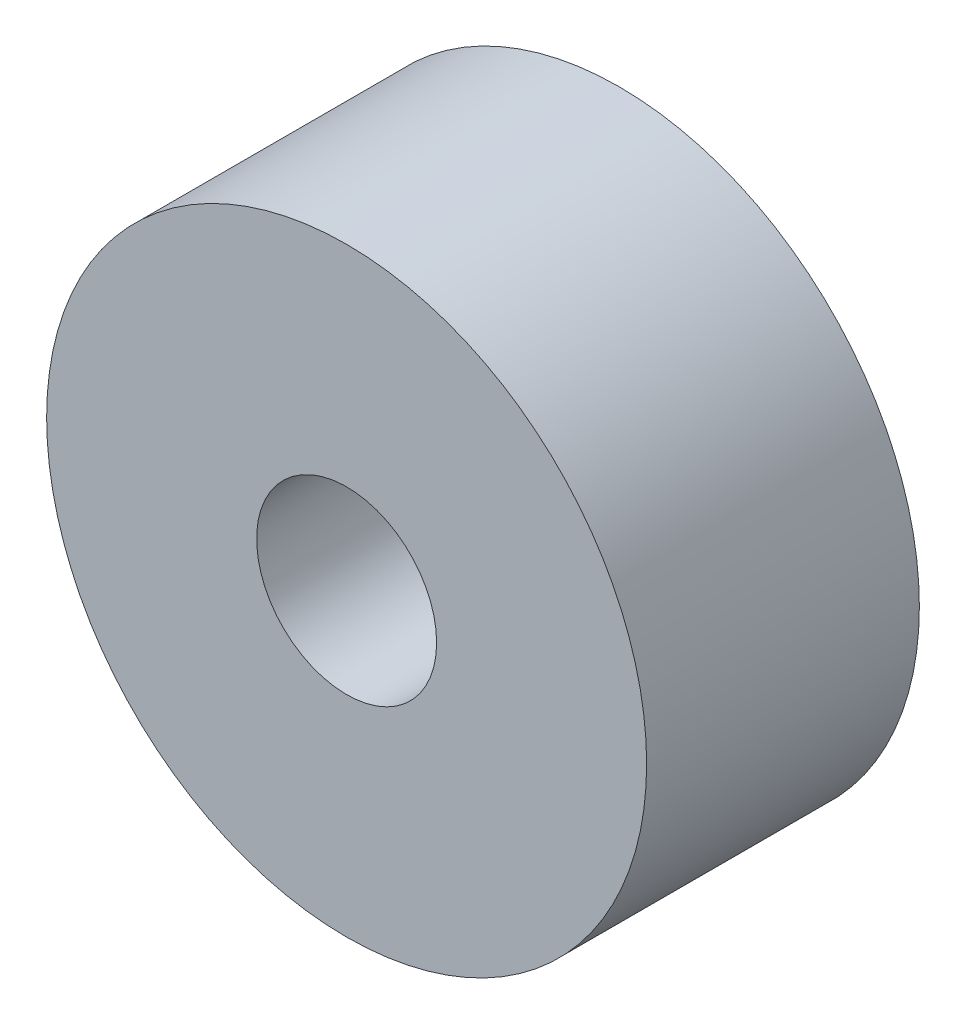
from build123d import *


with BuildPart() as part:
    # Sketch2 → Revolve1 (revolve)
    with BuildSketch(Plane(origin=(0, 0, 0), x_dir=(1, 0, 0), z_dir=(0, 1, 0))):
        Polygon((2.5, 2.5), (5.5, 2.5), (5.5, -2.5), (1.65, -2.5), (1.65, 0), (2.5, 0), align=None)
    revolve(axis=Axis((0, 0, 2.5), (0, 0, -1)))


solid = part.part
